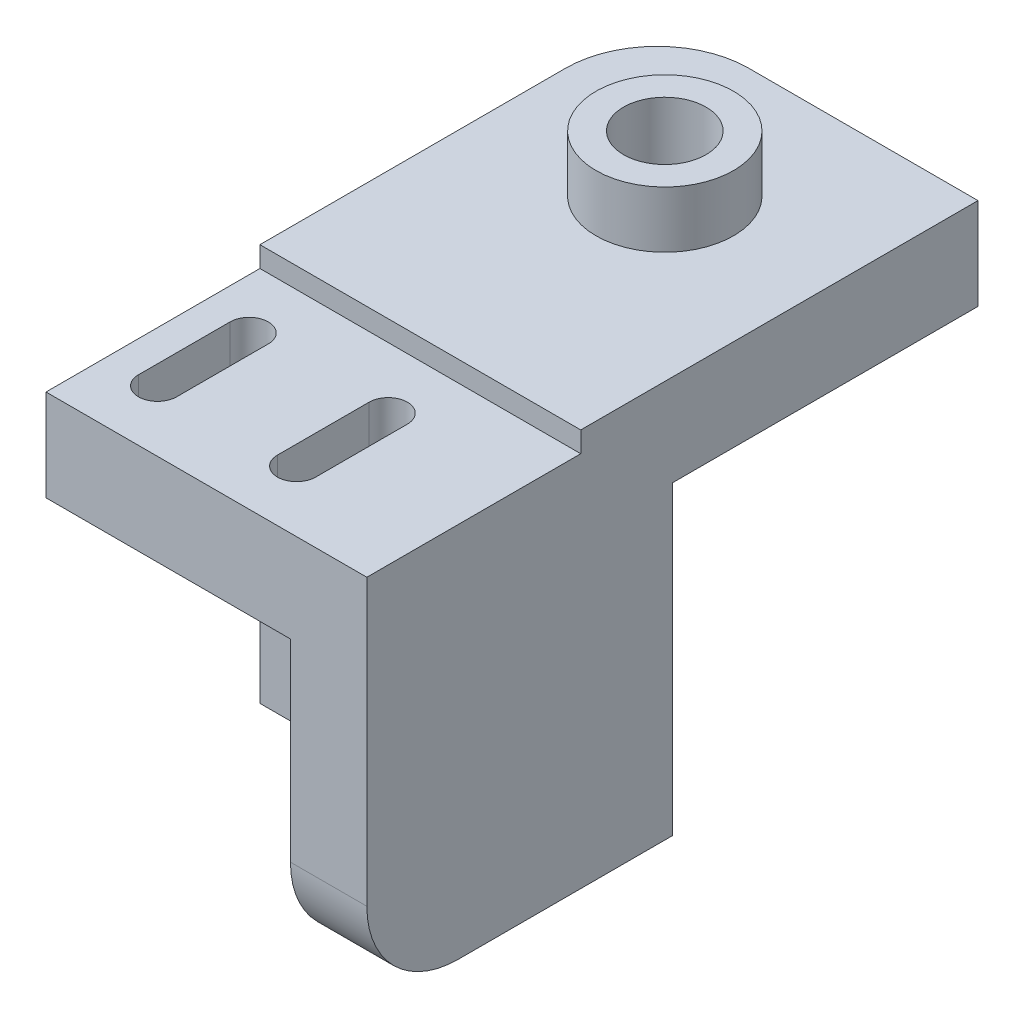
from build123d import *

# Parameters (mm, degrees)
SZKIC1_W                    = 21
SZKIC1_H                    = 6
SZKIC1_H_2                  = 20
SZKIC1_R                    = 2.7
DODANIE_WYCI_GNI_CIE1_DEPTH = 6
SZKIC2_W                    = 21
SZKIC2_H                    = 6
DODANIE_WYCI_GNI_CIE2_DEPTH = 20
SZKIC3_R                    = 2.7
WYTNIJ_WYCI_GNI_CIE1_DEPTH  = 9
SZKIC4_W                    = 21
SZKIC4_H                    = 6
DODANIE_WYCI_GNI_CIE3_DEPTH = 14
WYTNIJ_WYCI_GNI_CIE2_DEPTH  = 40.05
SZKIC6_R                    = 4.5
SZKIC6_R_2                  = 2.7
DODANIE_WYCI_GNI_CIE5_DEPTH = 3.7
ZAOKR_GLENIE2_R             = 6
SZKIC7_W                    = 5
SZKIC7_H                    = 18.65
DODANIE_WYCI_GNI_CIE6_DEPTH = 14
ZAOKR_GLENIE3_R             = 6


with BuildPart() as part:
    # Szkic1 → Dodanie-wyciągnięcie1 (new body)
    with BuildSketch(Plane.XY):
        with Locations((10.5, 23)):
            Rectangle(SZKIC1_W, SZKIC1_H)
        with Locations((10.5, 10)):
            Rectangle(SZKIC1_W, SZKIC1_H_2)
        with Locations((8, 10)):
            Circle(SZKIC1_R, mode=Mode.SUBTRACT)
    extrude(amount=DODANIE_WYCI_GNI_CIE1_DEPTH)

    # Szkic2 → Dodanie-wyciągnięcie2 (add)
    with BuildSketch(Plane(origin=(0, 0, 0), x_dir=(-1, 0, 0), z_dir=(0, 0, -1))):
        with Locations((-10.5, 23)):
            Rectangle(SZKIC2_W, SZKIC2_H)
    extrude(amount=DODANIE_WYCI_GNI_CIE2_DEPTH)

    # Szkic3 → Wytnij-wyciągnięcie1 (cut)
    with BuildSketch(Plane(origin=(0, 26, 0), x_dir=(1, 0, 0), z_dir=(0, 1, 0))):
        with Locations((10.5, 10)):
            Circle(SZKIC3_R)
    extrude(amount=-WYTNIJ_WYCI_GNI_CIE1_DEPTH, mode=Mode.SUBTRACT)

    # Szkic4 → Dodanie-wyciągnięcie3 (add)
    with BuildSketch(Plane.XY.offset(6)):
        with Locations((10.5, 21.65)):
            Rectangle(SZKIC4_W, SZKIC4_H)
    extrude(amount=DODANIE_WYCI_GNI_CIE3_DEPTH)

    # Szkic5 → Wytnij-wyciągnięcie2 (cut)
    with BuildSketch(Plane(origin=(0, 24.65, 0), x_dir=(1, 0, 0), z_dir=(0, 1, 0))):
        with BuildLine():
            Line((2.05, -16), (2.05, -10))
            ThreePointArc((2.05, -10), (3.3, -8.75), (4.55, -10))
            Line((4.55, -10), (4.55, -16))
            ThreePointArc((4.55, -16), (3.3, -17.25), (2.05, -16))
        make_face()
        with BuildLine():
            Line((13.65, -16), (13.65, -10))
            ThreePointArc((13.65, -10), (12.4, -8.75), (11.15, -10))
            Line((11.15, -10), (11.15, -16))
            ThreePointArc((11.15, -16), (12.4, -17.25), (13.65, -16))
        make_face()
    extrude(amount=-WYTNIJ_WYCI_GNI_CIE2_DEPTH, mode=Mode.SUBTRACT)

    # Szkic6 → Dodanie-wyciągnięcie5 (add)
    with BuildSketch(Plane(origin=(0, 26, 0), x_dir=(1, 0, 0), z_dir=(0, 1, 0))):
        with Locations((10.5, 10)):
            Circle(SZKIC6_R)
        with Locations((10.5, 10)):
            Circle(SZKIC6_R_2, mode=Mode.SUBTRACT)
    extrude(amount=DODANIE_WYCI_GNI_CIE5_DEPTH)

    # Zaokrąglenie2
    zaokr_glenie2_edges = [part.edges().sort_by_distance(p)[0] for p in [
        (0, 23, -20),
    ]]
    fillet(zaokr_glenie2_edges, radius=ZAOKR_GLENIE2_R)

    # Szkic7 → Dodanie-wyciągnięcie6 (add)
    with BuildSketch(Plane.XY.offset(6)):
        with Locations((18.5, 9.325)):
            Rectangle(SZKIC7_W, SZKIC7_H)
    extrude(amount=DODANIE_WYCI_GNI_CIE6_DEPTH)

    # Zaokrąglenie3
    zaokr_glenie3_edges = [part.edges().sort_by_distance(p)[0] for p in [
        (18.5, 0, 20),
    ]]
    fillet(zaokr_glenie3_edges, radius=ZAOKR_GLENIE3_R)


solid = part.part
